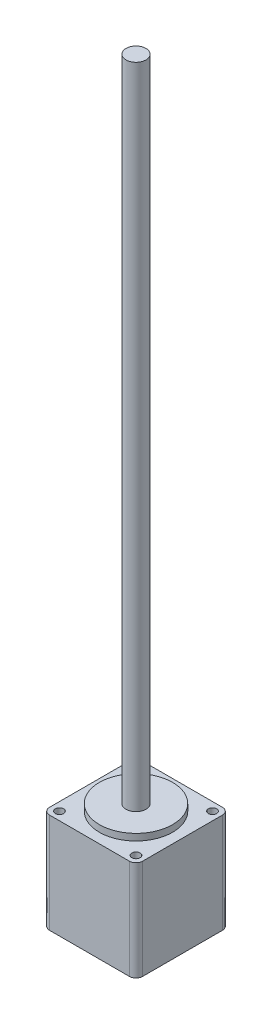
from build123d import *

# Parameters (mm, degrees)
SKETCH1_W           = 28
SKETCH1_H           = 28
SKETCH1_R           = 1.25
BOSS_EXTRUDE1_DEPTH = 30
SKETCH2_R           = 11
BOSS_EXTRUDE2_DEPTH = 2
SKETCH3_R           = 3
BOSS_EXTRUDE3_DEPTH = 195
FILLET1_R           = 2


with BuildPart() as part:
    # Sketch1 → Boss-Extrude1 (new body)
    with BuildSketch(Plane(origin=(0, 0, 0), x_dir=(1, 0, 0), z_dir=(0, 1, 0))):
        with Locations((14, 14)):
            Rectangle(SKETCH1_W, SKETCH1_H)
        with Locations((2.5, 25.5)):
            Circle(SKETCH1_R, mode=Mode.SUBTRACT)
        with Locations((2.5, 2.5)):
            Circle(SKETCH1_R, mode=Mode.SUBTRACT)
        with Locations((25.5, 2.5)):
            Circle(SKETCH1_R, mode=Mode.SUBTRACT)
        with Locations((25.5, 25.5)):
            Circle(SKETCH1_R, mode=Mode.SUBTRACT)
    extrude(amount=BOSS_EXTRUDE1_DEPTH)

    # Sketch2 → Boss-Extrude2 (add)
    with BuildSketch(Plane(origin=(0, 30, 0), x_dir=(1, 0, 0), z_dir=(0, 1, 0))):
        with Locations((14, 14)):
            Circle(SKETCH2_R)
    extrude(amount=BOSS_EXTRUDE2_DEPTH)

    # Sketch3 → Boss-Extrude3 (add)
    with BuildSketch(Plane(origin=(0, 32, 0), x_dir=(1, 0, 0), z_dir=(0, 1, 0))):
        with Locations((14, 14)):
            Circle(SKETCH3_R)
    extrude(amount=BOSS_EXTRUDE3_DEPTH)

    # Fillet1
    fillet1_edges = [part.edges().sort_by_distance(p)[0] for p in [
        (0, 15, -28),
        (28, 15, -28),
        (28, 15, 0),
        (0, 15, 0),
    ]]
    fillet(fillet1_edges, radius=FILLET1_R)


solid = part.part
